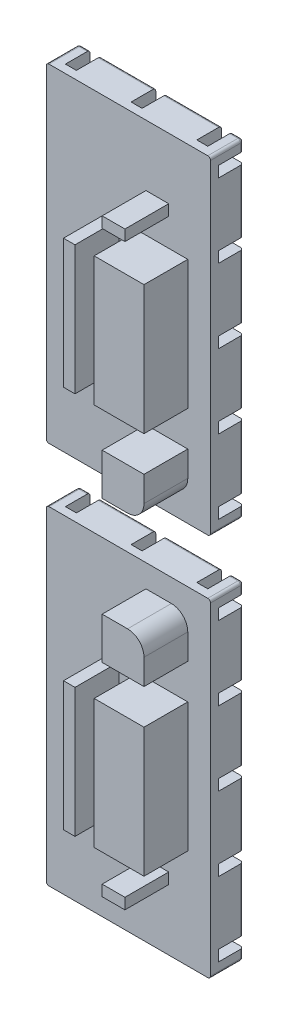
from build123d import *

# Parameters (mm, degrees)
SKETCH1_W          = 30
SKETCH1_H          = 60
COVER_DEPTH        = 6
SKETCH2_W          = 14.7
SKETCH2_H          = 44.7
PLUG_DEPTH         = 8
SKETCH3_W          = 30
SKETCH3_H          = 2
CUT_EXTRUDE1_DEPTH = 4.5
FILLET1_R          = 3
CUT_EXTRUDE2_DEPTH = 8
SKETCH5_W          = 2
SKETCH5_H          = 60
CUT_EXTRUDE3_DEPTH = 4.5
FILLET2_R          = 0.5
SKETCH6_R          = 0.408704467
CUT_EXTRUDE4_DEPTH = 0.2


with BuildPart() as part:
    # Sketch1 → cover (new body)
    with BuildSketch(Plane.XY):
        with Locations((15, 30)):
            Rectangle(SKETCH1_W, SKETCH1_H)
    extrude(amount=COVER_DEPTH)

    # Sketch2 → plug (add)
    with BuildSketch(Plane.XY.offset(6)):
        with Locations((18.5, 33.5)):
            Rectangle(SKETCH2_W, SKETCH2_H)
    extrude(amount=PLUG_DEPTH)

    # Sketch3 → Cut-Extrude1 (cut)
    with BuildSketch(Plane(origin=(0, 0, 0), x_dir=(-1, 0, 0), z_dir=(0, 0, -1))):
        with Locations((-15, 3)):
            Rectangle(SKETCH3_W, SKETCH3_H)
        with Locations((-15, 16.5)):
            Rectangle(SKETCH3_W, SKETCH3_H)
        with Locations((-15, 30)):
            Rectangle(SKETCH3_W, SKETCH3_H)
        with Locations((-15, 43.5)):
            Rectangle(SKETCH3_W, SKETCH3_H)
        with Locations((-15, 57)):
            Rectangle(SKETCH3_W, SKETCH3_H)
    extrude(amount=-CUT_EXTRUDE1_DEPTH, mode=Mode.SUBTRACT)

    # Fillet1
    fillet1_edges = [part.edges().sort_by_distance(p)[0] for p in [
        (11.15, 55.85, 10),
        (11.15, 11.15, 10),
        (25.85, 11.15, 10),
        (25.85, 55.85, 10),
    ]]
    fillet(fillet1_edges, radius=FILLET1_R)

    # Sketch4 → Cut-Extrude2 (cut)
    with BuildSketch(Plane(origin=(0, 0, 6), x_dir=(-1, 0, 0), z_dir=(0, 0, -1))):
        Polygon((0, 48.21), (-9.19636559, 48.21), (-9.19636559, 56.015412421), (-11.79, 56.015412421), (-11.79, 60), (-18.21, 60), (-18.21, 48.21), (-30, 48.21), (-30, 41.79), (-18.21, 41.79), (-16.75, 41.79), (-16.75, 18.21), (-18.21, 18.21), (-30, 18.21), (-30, 13.144889764), (-26.800253488, 13.144889764), (-26.800253488, 9.564317045), (-22.36831406, 9.564317045), (-22.36831406, 13.144889764), (-18.21, 13.144889764), (-18.21, 0), (-11.79, 0), (-11.79, 9.698270105), (-9.31972863, 13.144889764), (0, 13.144889764), (0, 18.21), (-11.79, 18.21), (-13.25, 18.21), (-13.25, 41.79), (-11.79, 41.79), (0, 41.79), align=None)
    extrude(amount=-CUT_EXTRUDE2_DEPTH, mode=Mode.SUBTRACT)

    # Sketch5 → Cut-Extrude3 (cut)
    with BuildSketch(Plane(origin=(0, 0, 0), x_dir=(-1, 0, 0), z_dir=(0, 0, -1))):
        with Locations((-27, 30)):
            Rectangle(SKETCH5_W, SKETCH5_H)
        with Locations((-15, 30)):
            Rectangle(SKETCH5_W, SKETCH5_H)
        with Locations((-3, 30)):
            Rectangle(SKETCH5_W, SKETCH5_H)
    extrude(amount=-CUT_EXTRUDE3_DEPTH, mode=Mode.SUBTRACT)

    # Fillet2
    fillet2_edges = [part.edges().sort_by_distance(p)[0] for p in [
        (0, 50.25, 0),
        (0, 36.75, 0),
        (0, 23.25, 0),
        (0, 9.75, 0),
        (0, 1, 0),
        (30, 9.75, 0),
        (30, 23.25, 0),
        (30, 36.75, 0),
        (30, 50.25, 0),
        (21, 60, 0),
        (9, 60, 0),
        (1, 60, 0),
        (30, 59, 0),
        (9, 0, 0),
        (21, 0, 0),
        (29, 0, 0),
        (29, 60, 0),
        (30, 1, 0),
        (1, 0, 0),
        (0, 59, 0),
        (0, 60, 3),
        (30, 60, 3),
        (30, 0, 3),
        (0, 0, 3),
    ]]
    fillet(fillet2_edges, radius=FILLET2_R)

    # Sketch6 → Cut-Extrude4 (cut)
    with BuildSketch(Plane(origin=(0, 0, 0), x_dir=(-1, 0, 0), z_dir=(0, 0, -1))):
        with Locations((-1.25, 1.25)):
            Circle(SKETCH6_R)
    extrude(amount=-CUT_EXTRUDE4_DEPTH, mode=Mode.SUBTRACT)


with BuildPart() as body_2:
    # Mirror3: mirrored copy
    add(part.part.mirror(Plane.ZX.offset(65)))


solid = Compound([part.part, body_2.part])
